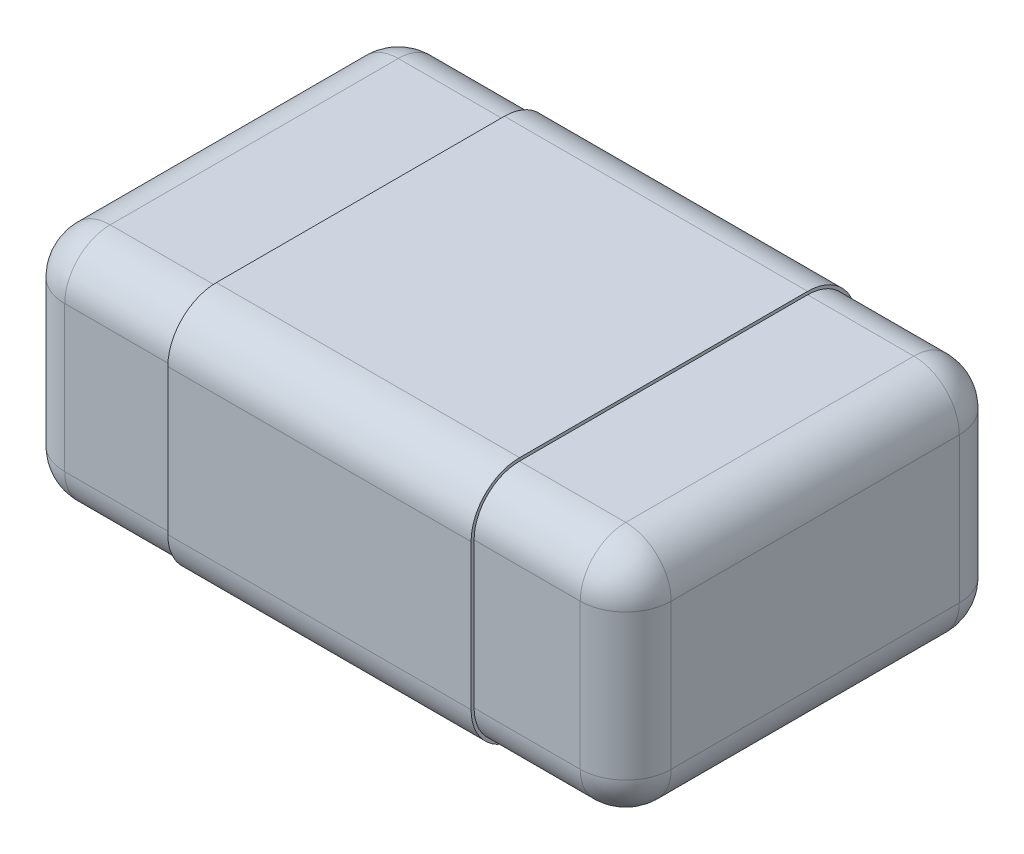
from build123d import *

# Parameters (mm, degrees)
ESBO_O1_W                     = 2
ESBO_O1_H                     = 1.25
RESSALTO_EXTRUS_O1_DEPTH      = 0.78
FILETE1_R                     = 0.15
RESSALTO_EXTRUS_O4_DEPTH      = 0.5
RESSALTO_EXTRUS_O4_DEPTH_BACK = 0.5
RESSALTO_EXTRUS_O5_DEPTH      = 0.02


with BuildPart() as part:
    # Esboço1 → Ressalto-extrusão1 (new body)
    with BuildSketch(Plane(origin=(0, 0, 0), x_dir=(1, 0, 0), z_dir=(0, 1, 0))):
        Rectangle(ESBO_O1_W, ESBO_O1_H)
    extrude(amount=-RESSALTO_EXTRUS_O1_DEPTH)

    # Filete1
    filete1_edges = [part.edges().sort_by_distance(p)[0] for p in [
        (1, -0.78, 0),
        (0, -0.78, -0.625),
        (-1, -0.78, 0),
        (0, 0, -0.625),
        (1, 0, 0),
        (0, 0, 0.625),
        (-1, 0, 0),
        (0, -0.78, 0.625),
        (-1, -0.39, -0.625),
        (1, -0.39, -0.625),
        (1, -0.39, 0.625),
        (-1, -0.39, 0.625),
    ]]
    fillet(filete1_edges, radius=FILETE1_R)

    # Esboço4 → Ressalto-extrusão4 (add, two sides)
    with BuildSketch(Plane(origin=(0, 0, 0), x_dir=(0, 0, -1), z_dir=(1, 0, 0))) as ressalto_extrus_o4_sk:
        with BuildLine():
            Line((0.635, -0.63), (0.635, -0.15))
            ThreePointArc((0.635, -0.15), (0.588137085, -0.036862915), (0.475, 0.01))
            Line((0.475, 0.01), (-0.475, 0.01))
            ThreePointArc((-0.475, 0.01), (-0.588137085, -0.036862915), (-0.635, -0.15))
            Line((-0.635, -0.15), (-0.635, -0.63))
            ThreePointArc((-0.635, -0.63), (-0.588137085, -0.743137085), (-0.475, -0.79))
            Line((-0.475, -0.79), (0.475, -0.79))
            ThreePointArc((0.475, -0.79), (0.588137085, -0.743137085), (0.635, -0.63))
        make_face()
        with BuildLine():
            Line((0.625, -0.63), (0.625, -0.15))
            ThreePointArc((0.625, -0.15), (0.581066017, -0.043933983), (0.475, 0))
            Line((0.475, 0), (-0.475, 0))
            ThreePointArc((-0.475, 0), (-0.581066017, -0.043933983), (-0.625, -0.15))
            Line((-0.625, -0.15), (-0.625, -0.63))
            ThreePointArc((-0.625, -0.63), (-0.581066017, -0.736066017), (-0.475, -0.78))
            Line((-0.475, -0.78), (0.475, -0.78))
            ThreePointArc((0.475, -0.78), (0.581066017, -0.736066017), (0.625, -0.63))
        make_face(mode=Mode.SUBTRACT)
    extrude(amount=RESSALTO_EXTRUS_O4_DEPTH)
    extrude(ressalto_extrus_o4_sk.sketch, amount=-RESSALTO_EXTRUS_O4_DEPTH_BACK)

    # Esboço2 → Ressalto-extrusão5 (add)
    with BuildSketch(Plane(origin=(0, -0.79, 0), x_dir=(0, 0, 1), z_dir=(0, -1, 0))):
        with BuildLine():
            Line((0.240411447, -0.227848101), (0.240411447, -0.449367089))
            Line((0.240411447, -0.449367089), (0.151803852, -0.449367089))
            Line((0.151803852, -0.449367089), (0.151803852, -0.379746835))
            Line((0.151803852, -0.379746835), (-0.107689819, -0.379746835))
            Line((-0.107689819, -0.379746835), (-0.107689819, -0.449367089))
            Line((-0.107689819, -0.449367089), (-0.1899683, -0.449367089))
            add(Edge.make_bspline(
                [(-0.1899683, -0.449367089), (-0.19012994, -0.444249723), (-0.190452713, -0.434031056), (-0.192371039, -0.421451182), (-0.194625359, -0.411846862), (-0.196936571, -0.40541324), (-0.199537979, -0.399615701), (-0.201880811, -0.396296502), (-0.203022097, -0.394679589)],
                knots=[0, 0, 0, 0, 1.613816483, 3.222566973, 4.00434643, 4.721272461, 5.377081126, 6, 6, 6, 6], degree=3))
            add(Edge.make_bspline(
                [(-0.203022097, -0.394679589), (-0.204461211, -0.392957177), (-0.20735537, -0.389493284), (-0.212568341, -0.384991041), (-0.218600713, -0.381270226), (-0.225242397, -0.377986704), (-0.232653657, -0.375269127), (-0.24089787, -0.373371747), (-0.249954795, -0.371959143), (-0.256286804, -0.371552842), (-0.259588553, -0.371340981)],
                knots=[0, 0, 0, 0, 0.85147813, 1.712383349, 2.601498934, 3.536495334, 4.522642149, 5.591462363, 6.74409729, 8, 8, 8, 8], degree=3))
            Line((-0.259588553, -0.371340981), (-0.259588553, -0.297468354))
            Line((-0.259588553, -0.297468354), (0.151803852, -0.297468354))
            Line((0.151803852, -0.297468354), (0.151803852, -0.227848101))
            Line((0.151803852, -0.227848101), (0.240411447, -0.227848101))
        make_face()
        with BuildLine():
            Line((0.240411447, 0.120886076), (0.240411447, -0.125949367))
            Line((0.240411447, -0.125949367), (0.158330751, -0.125949367))
            add(Edge.make_bspline(
                [(0.158330751, -0.125949367), (0.152214367, -0.120887492), (0.140208237, -0.110951304), (0.12230397, -0.0966561), (0.104986645, -0.083034363), (0.088088852, -0.070297559), (0.071638652, -0.058342649), (0.055729879, -0.0469833), (0.04010761, -0.036552305), (0.02977976, -0.029910657), (0.024727112, -0.026661392)],
                knots=[0, 0, 0, 0, 1.143871494, 2.245357909, 3.300914739, 4.318253735, 5.293884102, 6.230829319, 7.13447631, 8, 8, 8, 8], degree=3))
            add(Edge.make_bspline(
                [(0.024727112, -0.026661392), (0.018467772, -0.022807477), (0.00649251, -0.01543423), (-0.011299949, -0.005831909), (-0.027841839, 0.002212488), (-0.043428254, 0.008711535), (-0.058501424, 0.013740093), (-0.073657737, 0.017037996), (-0.088968207, 0.019226969), (-0.099276497, 0.019489231), (-0.104426369, 0.019620253)],
                knots=[0, 0, 0, 0, 1.267768508, 2.425473269, 3.486024264, 4.439590646, 5.336903618, 6.222592004, 7.112032784, 8, 8, 8, 8], degree=3))
            add(Edge.make_bspline(
                [(-0.104426369, 0.019620253), (-0.109973533, 0.019457389), (-0.120442742, 0.019150014), (-0.135183808, 0.016680702), (-0.147862366, 0.012207249), (-0.158544157, 0.006120486), (-0.16699737, -0.001718213), (-0.172986786, -0.011118674), (-0.176714501, -0.021909536), (-0.177106684, -0.029597078), (-0.177310072, -0.033583861)],
                knots=[0, 0, 0, 0, 1.306909451, 2.466541577, 3.505869428, 4.459795217, 5.344572835, 6.193571478, 7.063180651, 8, 8, 8, 8], degree=3))
            add(Edge.make_bspline(
                [(-0.177310072, -0.033583861), (-0.177088445, -0.037797417), (-0.176649647, -0.046139784), (-0.172906717, -0.058228164), (-0.167362161, -0.069794193), (-0.162961227, -0.077292083), (-0.160696148, -0.081151108)],
                knots=[0, 0, 0, 0, 0.988472559, 1.957064427, 2.948539211, 4, 4, 4, 4], degree=3))
            add(Edge.make_bspline(
                [(-0.160696148, -0.081151108), (-0.158162705, -0.084765881), (-0.153335217, -0.091653849), (-0.14551733, -0.100442138), (-0.138585493, -0.107235065), (-0.134646389, -0.111371202), (-0.133006275, -0.113093354)],
                knots=[0, 0, 0, 0, 1.249878488, 2.381649198, 3.326171657, 4, 4, 4, 4], degree=3))
            Line((-0.133006275, -0.113093354), (-0.133006275, -0.119620253))
            Line((-0.133006275, -0.119620253), (-0.241293458, -0.119620253))
            add(Edge.make_bspline(
                [(-0.241293458, -0.119620253), (-0.243030602, -0.116915918), (-0.246833272, -0.110996035), (-0.251734635, -0.100573059), (-0.256834934, -0.088217246), (-0.26197876, -0.074279085), (-0.266458759, -0.059444232), (-0.269739252, -0.04443776), (-0.271805277, -0.029718517), (-0.272101339, -0.019975966), (-0.272246781, -0.015189873)],
                knots=[0, 0, 0, 0, 0.69970136, 1.531670699, 2.504079761, 3.612943238, 4.767349377, 5.877514774, 6.957315063, 8, 8, 8, 8], degree=3))
            add(Edge.make_bspline(
                [(-0.272246781, -0.015189873), (-0.272145838, -0.010272103), (-0.271949257, -0.000695027), (-0.270052265, 0.013195591), (-0.266883874, 0.026152524), (-0.262513205, 0.038190645), (-0.2570145, 0.049402474), (-0.24997581, 0.059529553), (-0.241814993, 0.068790356), (-0.232475839, 0.077159072), (-0.221906303, 0.084420345), (-0.21043315, 0.090921092), (-0.197820463, 0.096215142), (-0.184283525, 0.100709579), (-0.169658558, 0.103983447), (-0.154107163, 0.106468649), (-0.137518514, 0.107964222), (-0.126119876, 0.108138228), (-0.120249154, 0.108227848)],
                knots=[0, 0, 0, 0, 1.059873424, 2.064042983, 3.015596836, 3.930697506, 4.820695307, 5.699957467, 6.581199529, 7.477193696, 8.396013015, 9.341094634, 10.315416404, 11.340324501, 12.412707035, 13.542640562, 14.734368785, 16, 16, 16, 16], degree=3))
            add(Edge.make_bspline(
                [(-0.120249154, 0.108227848), (-0.112856677, 0.108059762), (-0.098089689, 0.107723999), (-0.076109458, 0.104913559), (-0.054324675, 0.100623497), (-0.032644635, 0.094266035), (-0.010659972, 0.085942561), (0.01194365, 0.075421379), (0.035218138, 0.062351564), (0.050657644, 0.052374248), (0.058647207, 0.047211234)],
                knots=[0, 0, 0, 0, 0.92383478, 1.845424201, 2.765944236, 3.697111989, 4.666093288, 5.70224482, 6.810968485, 8, 8, 8, 8], degree=3))
            add(Edge.make_bspline(
                [(0.058647207, 0.047211234), (0.063540545, 0.043836713), (0.073096713, 0.037246632), (0.086879374, 0.027223149), (0.099855338, 0.017352653), (0.111778424, 0.007693196), (0.122497499, -0.001175041), (0.13166194, -0.008894608), (0.139184524, -0.015177183), (0.143567164, -0.018975648), (0.145474738, -0.020628956)],
                knots=[0, 0, 0, 0, 1.293836837, 2.526725554, 3.709287413, 4.842241028, 5.866627263, 6.737584004, 7.450524958, 8, 8, 8, 8], degree=3))
            Line((0.145474738, -0.020628956), (0.145474738, 0.120886076))
            Line((0.145474738, 0.120886076), (0.240411447, 0.120886076))
        make_face()
        with BuildLine():
            Line((0.240411447, 0.456962025), (0.240411447, 0.210126582))
            Line((0.240411447, 0.210126582), (0.158330751, 0.210126582))
            add(Edge.make_bspline(
                [(0.158330751, 0.210126582), (0.152214367, 0.215188458), (0.140208237, 0.225124645), (0.12230397, 0.239419849), (0.104986645, 0.253041586), (0.088088852, 0.26577839), (0.071638652, 0.277733301), (0.055729879, 0.289092649), (0.04010761, 0.299523645), (0.02977976, 0.306165292), (0.024727112, 0.309414557)],
                knots=[0, 0, 0, 0, 1.143871494, 2.245357909, 3.300914739, 4.318253735, 5.293884102, 6.230829319, 7.13447631, 8, 8, 8, 8], degree=3))
            add(Edge.make_bspline(
                [(0.024727112, 0.309414557), (0.018467772, 0.313268473), (0.00649251, 0.32064172), (-0.011299949, 0.33024404), (-0.027841839, 0.338288438), (-0.043428254, 0.344787485), (-0.058501424, 0.349816043), (-0.073657737, 0.353113945), (-0.088968207, 0.355302918), (-0.099276497, 0.35556518), (-0.104426369, 0.355696203)],
                knots=[0, 0, 0, 0, 1.267768508, 2.425473269, 3.486024264, 4.439590646, 5.336903618, 6.222592004, 7.112032784, 8, 8, 8, 8], degree=3))
            add(Edge.make_bspline(
                [(-0.104426369, 0.355696203), (-0.109973533, 0.355533338), (-0.120442742, 0.355225964), (-0.135183808, 0.352756651), (-0.147862366, 0.348283198), (-0.158544157, 0.342196435), (-0.16699737, 0.334357737), (-0.172986786, 0.324957276), (-0.176714501, 0.314166414), (-0.177106684, 0.306478871), (-0.177310072, 0.302492089)],
                knots=[0, 0, 0, 0, 1.306909451, 2.466541577, 3.505869428, 4.459795217, 5.344572835, 6.193571478, 7.063180651, 8, 8, 8, 8], degree=3))
            add(Edge.make_bspline(
                [(-0.177310072, 0.302492089), (-0.177088445, 0.298278533), (-0.176649647, 0.289936166), (-0.172906717, 0.277847785), (-0.167362161, 0.266281756), (-0.162961227, 0.258783866), (-0.160696148, 0.254924842)],
                knots=[0, 0, 0, 0, 0.988472559, 1.957064427, 2.948539211, 4, 4, 4, 4], degree=3))
            add(Edge.make_bspline(
                [(-0.160696148, 0.254924842), (-0.158162705, 0.251310068), (-0.153335217, 0.244422101), (-0.14551733, 0.235633811), (-0.138585493, 0.228840884), (-0.134646389, 0.224704747), (-0.133006275, 0.222982595)],
                knots=[0, 0, 0, 0, 1.249878488, 2.381649198, 3.326171657, 4, 4, 4, 4], degree=3))
            Line((-0.133006275, 0.222982595), (-0.133006275, 0.216455696))
            Line((-0.133006275, 0.216455696), (-0.241293458, 0.216455696))
            add(Edge.make_bspline(
                [(-0.241293458, 0.216455696), (-0.243030602, 0.219160031), (-0.246833272, 0.225079915), (-0.251734635, 0.23550289), (-0.256834934, 0.247858703), (-0.26197876, 0.261796864), (-0.266458759, 0.276631717), (-0.269739252, 0.29163819), (-0.271805277, 0.306357432), (-0.272101339, 0.316099983), (-0.272246781, 0.320886076)],
                knots=[0, 0, 0, 0, 0.69970136, 1.531670699, 2.504079761, 3.612943238, 4.767349377, 5.877514774, 6.957315063, 8, 8, 8, 8], degree=3))
            add(Edge.make_bspline(
                [(-0.272246781, 0.320886076), (-0.272145838, 0.325803846), (-0.271949257, 0.335380922), (-0.270052265, 0.349271541), (-0.266883874, 0.362228473), (-0.262513205, 0.374266594), (-0.2570145, 0.385478423), (-0.24997581, 0.395605503), (-0.241814993, 0.404866306), (-0.232475839, 0.413235021), (-0.221906303, 0.420496294), (-0.21043315, 0.426997042), (-0.197820463, 0.432291091), (-0.184283525, 0.436785528), (-0.169658558, 0.440059396), (-0.154107163, 0.442544598), (-0.137518514, 0.444040172), (-0.126119876, 0.444214178), (-0.120249154, 0.444303797)],
                knots=[0, 0, 0, 0, 1.059873424, 2.064042983, 3.015596836, 3.930697506, 4.820695307, 5.699957467, 6.581199529, 7.477193696, 8.396013015, 9.341094634, 10.315416404, 11.340324501, 12.412707035, 13.542640562, 14.734368785, 16, 16, 16, 16], degree=3))
            add(Edge.make_bspline(
                [(-0.120249154, 0.444303797), (-0.112856677, 0.444135712), (-0.098089689, 0.443799948), (-0.076109458, 0.440989509), (-0.054324675, 0.436699446), (-0.032644635, 0.430341984), (-0.010659972, 0.42201851), (0.01194365, 0.411497328), (0.035218138, 0.398427513), (0.050657644, 0.388450198), (0.058647207, 0.383287184)],
                knots=[0, 0, 0, 0, 0.92383478, 1.845424201, 2.765944236, 3.697111989, 4.666093288, 5.70224482, 6.810968485, 8, 8, 8, 8], degree=3))
            add(Edge.make_bspline(
                [(0.058647207, 0.383287184), (0.063540545, 0.379912662), (0.073096713, 0.373322582), (0.086879374, 0.363299098), (0.099855338, 0.353428602), (0.111778424, 0.343769145), (0.122497499, 0.334900909), (0.13166194, 0.327181341), (0.139184524, 0.320898767), (0.143567164, 0.317100301), (0.145474738, 0.315446994)],
                knots=[0, 0, 0, 0, 1.293836837, 2.526725554, 3.709287413, 4.842241028, 5.866627263, 6.737584004, 7.450524958, 8, 8, 8, 8], degree=3))
            Line((0.145474738, 0.315446994), (0.145474738, 0.456962025))
            Line((0.145474738, 0.456962025), (0.240411447, 0.456962025))
        make_face()
    extrude(amount=RESSALTO_EXTRUS_O5_DEPTH)


solid = part.part
